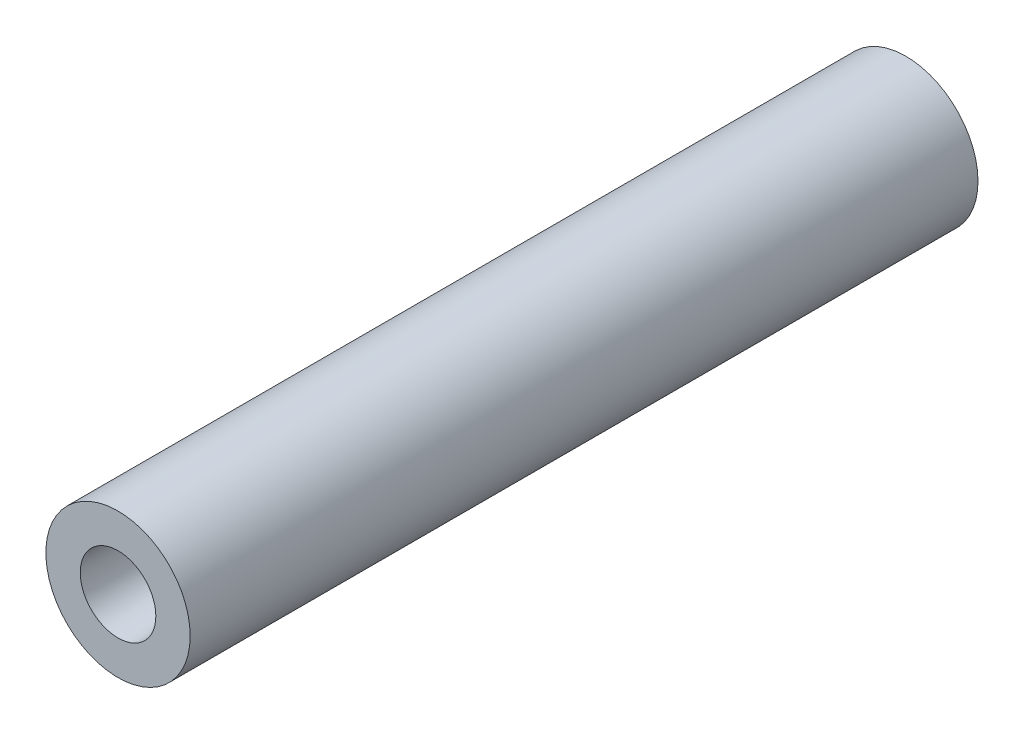
from build123d import *

# Parameters (mm, degrees)
SKETCH1_R           = 6
BOSS_EXTRUDE1_DEPTH = 65.5
SKETCH2_R           = 1
CUT_EXTRUDE1_DEPTH  = 66.5
SKETCH3_R           = 3.14325
CUT_EXTRUDE2_DEPTH  = 9.0297
CUT_EXTRUDE2_TAPER  = 2.328
SKETCH4_R           = 3.14325
CUT_EXTRUDE3_DEPTH  = 9.0297
CUT_EXTRUDE3_TAPER  = 2.328


with BuildPart() as part:
    # Sketch1 → Boss-Extrude1 (new body)
    with BuildSketch(Plane.XY):
        Circle(SKETCH1_R)
    extrude(amount=BOSS_EXTRUDE1_DEPTH)

    # Sketch2 → Cut-Extrude1 (cut, through all)
    with BuildSketch(Plane.XY):
        Circle(SKETCH2_R)
    extrude(amount=CUT_EXTRUDE1_DEPTH, mode=Mode.SUBTRACT)

    # Sketch3 → Cut-Extrude2 (cut)
    with BuildSketch(Plane.XY):
        Circle(SKETCH3_R)
    extrude(amount=CUT_EXTRUDE2_DEPTH, taper=CUT_EXTRUDE2_TAPER, mode=Mode.SUBTRACT)

    # Sketch4 → Cut-Extrude3 (cut)
    with BuildSketch(Plane.XY.offset(65.5)):
        Circle(SKETCH4_R)
    extrude(amount=-CUT_EXTRUDE3_DEPTH, taper=CUT_EXTRUDE3_TAPER, mode=Mode.SUBTRACT)


solid = part.part
